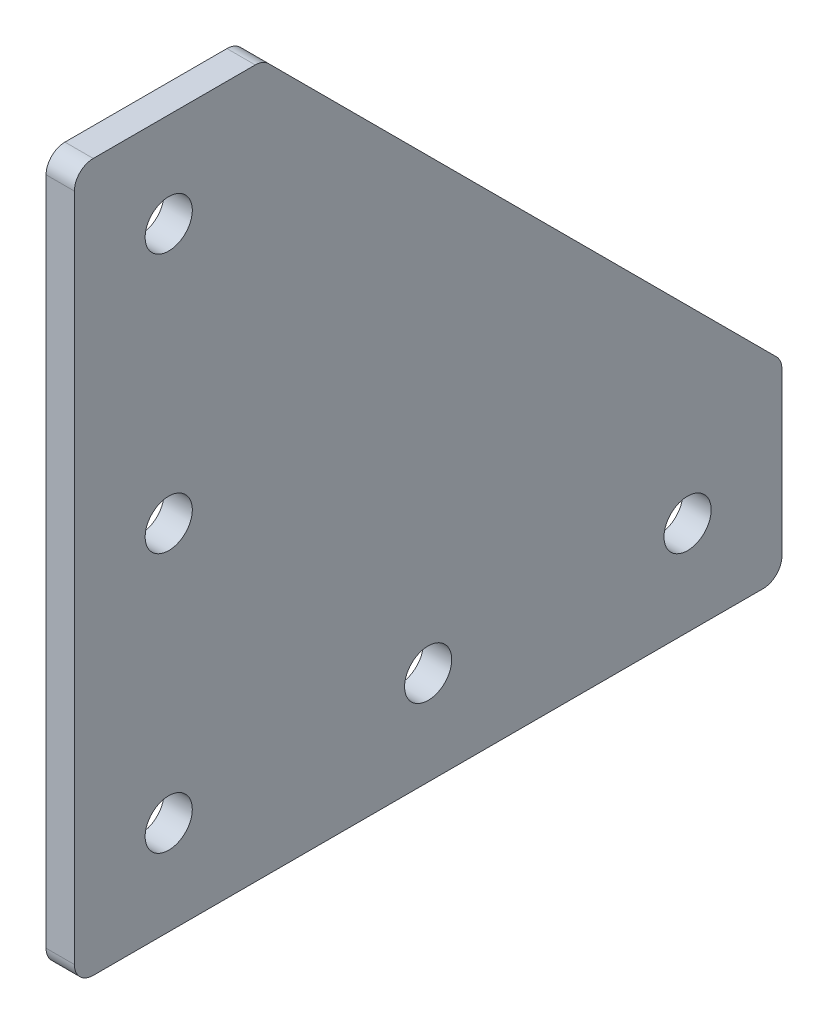
from build123d import *

# Parameters (mm, degrees)
SKETCH1_R           = 2.5
BOSS_EXTRUDE1_DEPTH = 3
FILLET1_R           = 2


with BuildPart() as part:
    # Sketch1 → Boss-Extrude1 (new body)
    with BuildSketch(Plane(origin=(0, 0, 0), x_dir=(0, 0, -1), z_dir=(1, 0, 0))):
        Polygon((75, 0), (0, 0), (0, 75), (20, 75), (75, 20), align=None)
        with Locations((65, 10)):
            Circle(SKETCH1_R, mode=Mode.SUBTRACT)
        with Locations((37.5, 10)):
            Circle(SKETCH1_R, mode=Mode.SUBTRACT)
        with Locations((10, 10)):
            Circle(SKETCH1_R, mode=Mode.SUBTRACT)
        with Locations((10, 65)):
            Circle(SKETCH1_R, mode=Mode.SUBTRACT)
        with Locations((10, 37.5)):
            Circle(SKETCH1_R, mode=Mode.SUBTRACT)
    extrude(amount=BOSS_EXTRUDE1_DEPTH)

    # Fillet1
    fillet1_edges = [part.edges().sort_by_distance(p)[0] for p in [
        (1.5, 0, -75),
        (1.5, 0, 0),
        (1.5, 75, 0),
        (1.5, 75, -20),
        (1.5, 20, -75),
    ]]
    fillet(fillet1_edges, radius=FILLET1_R)


solid = part.part
